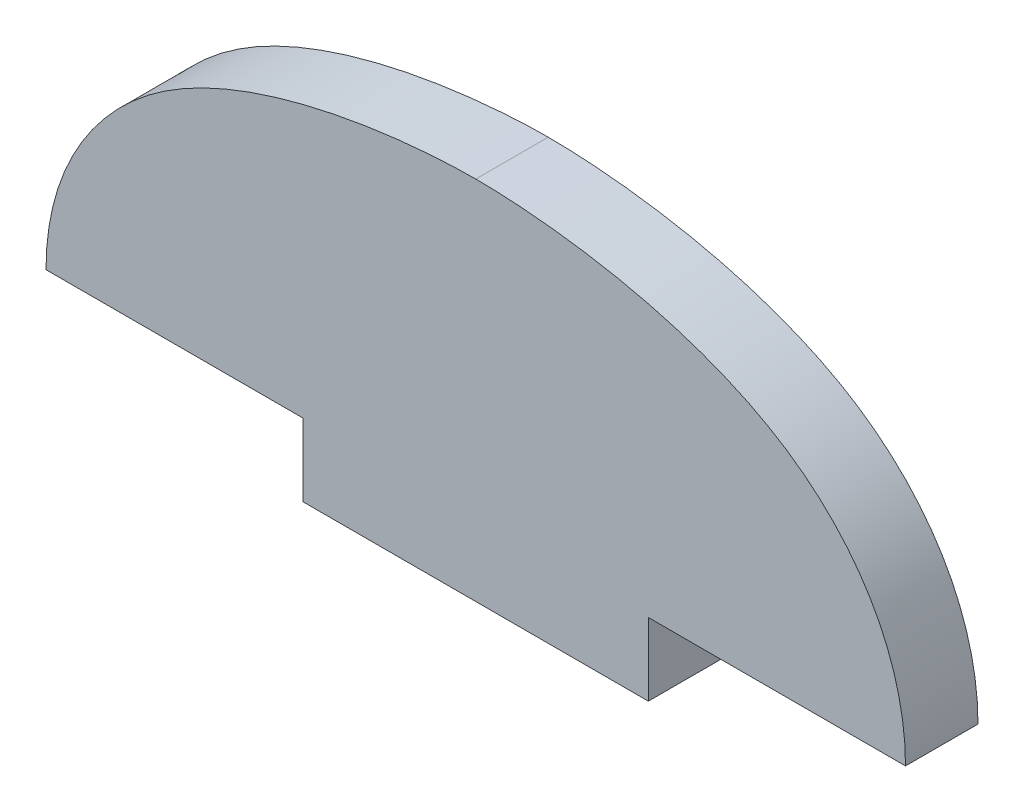
from build123d import *

# Parameters (mm, degrees)
SKETCH1_W           = 25.4
SKETCH1_H           = 5.334
BOSS_EXTRUDE1_DEPTH = 5.334


with BuildPart() as part:
    # Sketch1 → Boss-Extrude1 (new body)
    with BuildSketch(Plane.XY):
        with BuildLine():
            Line((-31.623, 41.4528), (31.623, 41.4528))
            add(Edge.make_bspline(
                [(31.623, 41.4528), (31.623, 47.941390823), (23.890768101, 61.043784375), (5.255194173, 63.0428), (0, 63.0428)],
                knots=[0, 0, 0, 0, 0.432269255, 1, 1, 1, 1], degree=3))
            add(Edge.make_bspline(
                [(-31.623, 41.4528), (-31.623, 47.941390823), (-23.890768101, 61.043784375), (-5.255194173, 63.0428), (0, 63.0428)],
                knots=[0, 0, 0, 0, 0.432269255, 1, 1, 1, 1], degree=3))
        make_face()
        with Locations((0, 38.7858)):
            Rectangle(SKETCH1_W, SKETCH1_H)
    extrude(amount=BOSS_EXTRUDE1_DEPTH)


solid = part.part
